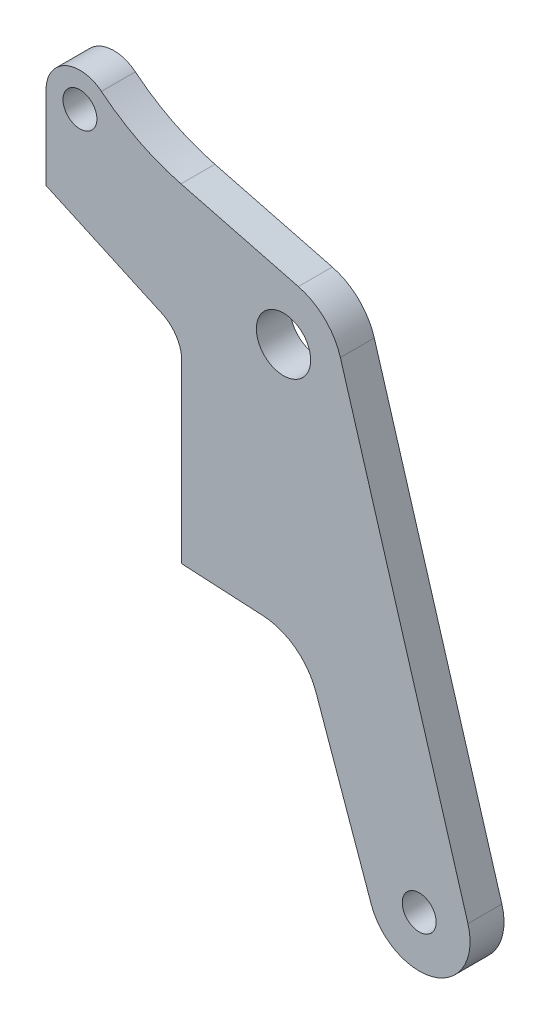
from build123d import *

# Parameters (mm, degrees)
SKETCH_1_R      = 1
SKETCH_1_R_2    = 1.6
EXTRUDE_1_DEPTH = 1


with BuildPart() as part:
    # 草图1 → 凸台-拉伸1 (new body, symmetric)
    with BuildSketch(Plane.XY):
        with BuildLine():
            Line((0.874328329, 3.389033782), (-6.043528055, 5.173754207))
            ThreePointArc((-6.043528055, 5.173754207), (-8.518069078, 6.106819418), (-10.734845082, 7.548994201))
            ThreePointArc((-10.734845082, 7.548994201), (-12.857231055, 7.806973967), (-14, 6))
            Line((-14, 6), (-14, 1.110000054))
            Line((-14, 1.110000054), (-7.170013537, -2.005324011))
            ThreePointArc((-7.170013537, -2.005324011), (-6.317743639, -2.743301367), (-6, -3.824973007))
            Line((-6, -3.824973007), (-6, -14.200378782))
            Line((-6, -14.200378782), (-1.20605244, -14.456265808))
            ThreePointArc((-1.20605244, -14.456265808), (0.702747897, -15.147812467), (1.906524604, -16.782644918))
            Line((1.906524604, -16.782644918), (5.172173145, -26.001696201))
            ThreePointArc((5.172173145, -26.001696201), (8.931003799, -27.851882173), (10.874170567, -24.140265418))
            Line((10.874170567, -24.140265418), (3.353198995, 1.003023678))
            ThreePointArc((3.353198995, 1.003023678), (2.427191355, 2.521654641), (0.874328329, 3.389033782))
        make_face()
        with Locations((-12, 6)):
            Circle(SKETCH_1_R, mode=Mode.SUBTRACT)
        with Locations((8, -25)):
            Circle(SKETCH_1_R, mode=Mode.SUBTRACT)
        Circle(SKETCH_1_R_2, mode=Mode.SUBTRACT)
    extrude(amount=EXTRUDE_1_DEPTH, both=True)


solid = part.part
